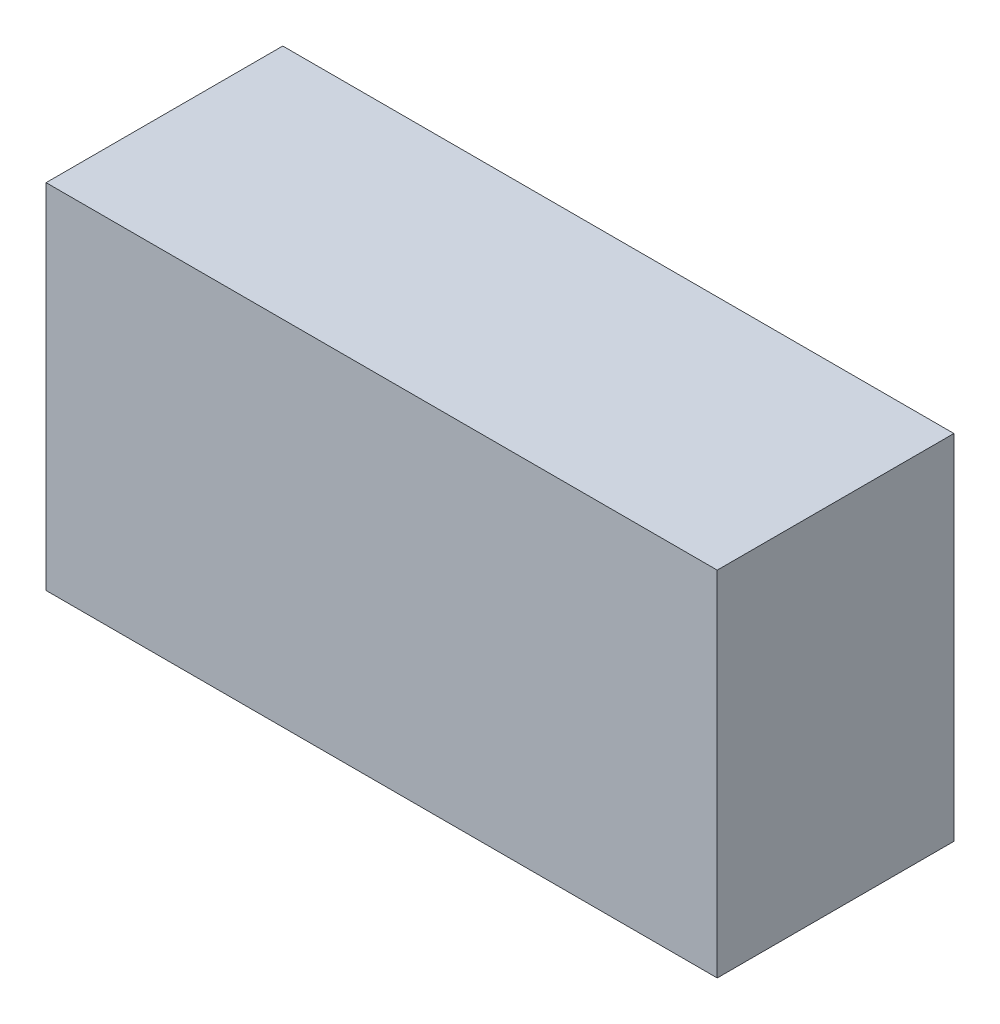
from build123d import *

# Parameters (mm, degrees)
SKETCH1_W           = 48.26
SKETCH1_H           = 25.4
BOSS_EXTRUDE1_DEPTH = 17.018


with BuildPart() as part:
    # Sketch1 → Boss-Extrude1 (new body)
    with BuildSketch(Plane.XY):
        with Locations((24.13, 12.7)):
            Rectangle(SKETCH1_W, SKETCH1_H)
    extrude(amount=BOSS_EXTRUDE1_DEPTH)


solid = part.part
